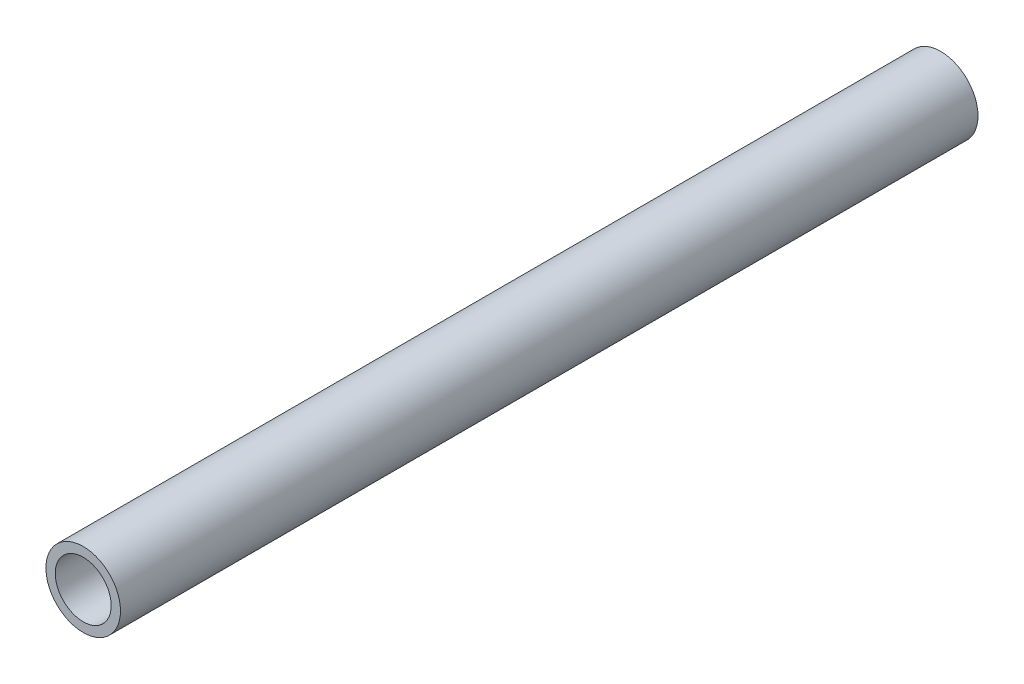
from build123d import *

# Parameters (mm, degrees)
SKETCH1_R           = 12.7
SKETCH1_R_2         = 9.525
BOSS_EXTRUDE1_DEPTH = 292.1


with BuildPart() as part:
    # Sketch1 → Boss-Extrude1 (new body)
    with BuildSketch(Plane.XY):
        Circle(SKETCH1_R)
        Circle(SKETCH1_R_2, mode=Mode.SUBTRACT)
    extrude(amount=BOSS_EXTRUDE1_DEPTH)


solid = part.part
